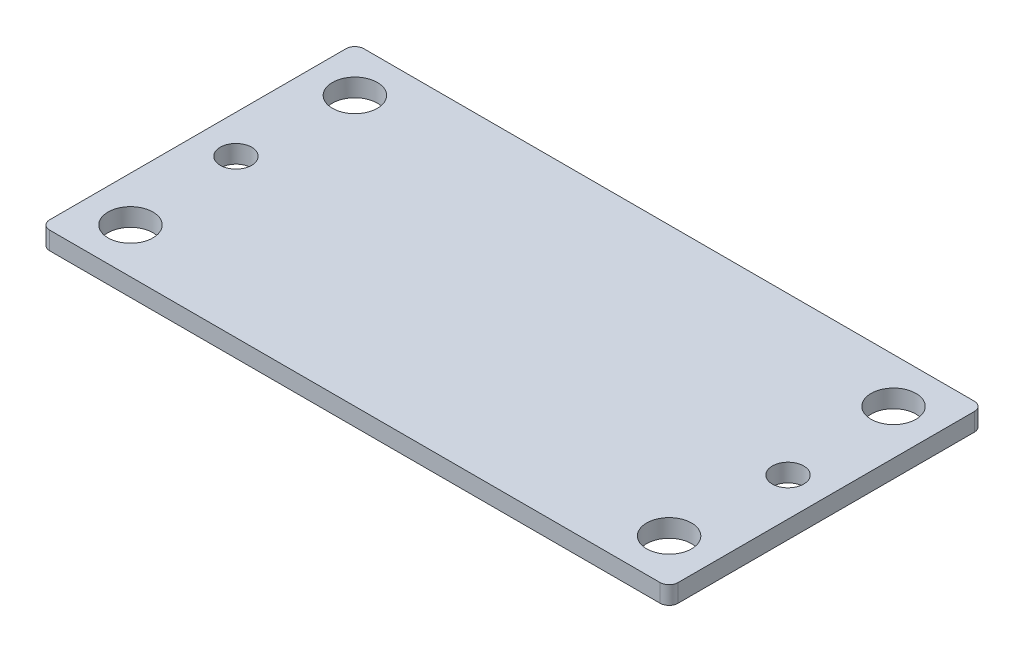
from build123d import *

# Parameters (mm, degrees)
SKETCH1_W               = 70
SKETCH1_H               = 35
BOSS_EXTRUDE1_DEPTH     = 2
SKETCH2_R               = 2.5
SKETCH2_R_2             = 1.75
CUT_EXTRUDE1_DEPTH      = 1
CUT_EXTRUDE1_DEPTH_BACK = 3
FILLET1_R               = 1


with BuildPart() as part:
    # Sketch1 → Boss-Extrude1 (new body)
    with BuildSketch(Plane(origin=(0, 0, 0), x_dir=(1, 0, 0), z_dir=(0, 1, 0))):
        with Locations((35, 17.5)):
            Rectangle(SKETCH1_W, SKETCH1_H)
    extrude(amount=BOSS_EXTRUDE1_DEPTH)

    # Sketch2 → Cut-Extrude1 (cut, two sides)
    with BuildSketch(Plane(origin=(0, 2, 0), x_dir=(1, 0, 0), z_dir=(0, 1, 0))) as cut_extrude1_sk:
        with Locations((5, 30)):
            Circle(SKETCH2_R)
        with Locations((5, 5)):
            Circle(SKETCH2_R)
        with Locations((4.25, 17.5)):
            Circle(SKETCH2_R_2)
        with Locations((65.75, 17.5)):
            Circle(SKETCH2_R_2)
        with Locations((65, 5)):
            Circle(SKETCH2_R)
        with Locations((65, 30)):
            Circle(SKETCH2_R)
    extrude(amount=CUT_EXTRUDE1_DEPTH, mode=Mode.SUBTRACT)
    extrude(cut_extrude1_sk.sketch, amount=-CUT_EXTRUDE1_DEPTH_BACK, mode=Mode.SUBTRACT)

    # Fillet1
    fillet1_edges = [part.edges().sort_by_distance(p)[0] for p in [
        (0, 1, -35),
        (70, 1, -35),
        (70, 1, 0),
        (0, 1, 0),
    ]]
    fillet(fillet1_edges, radius=FILLET1_R)


solid = part.part
